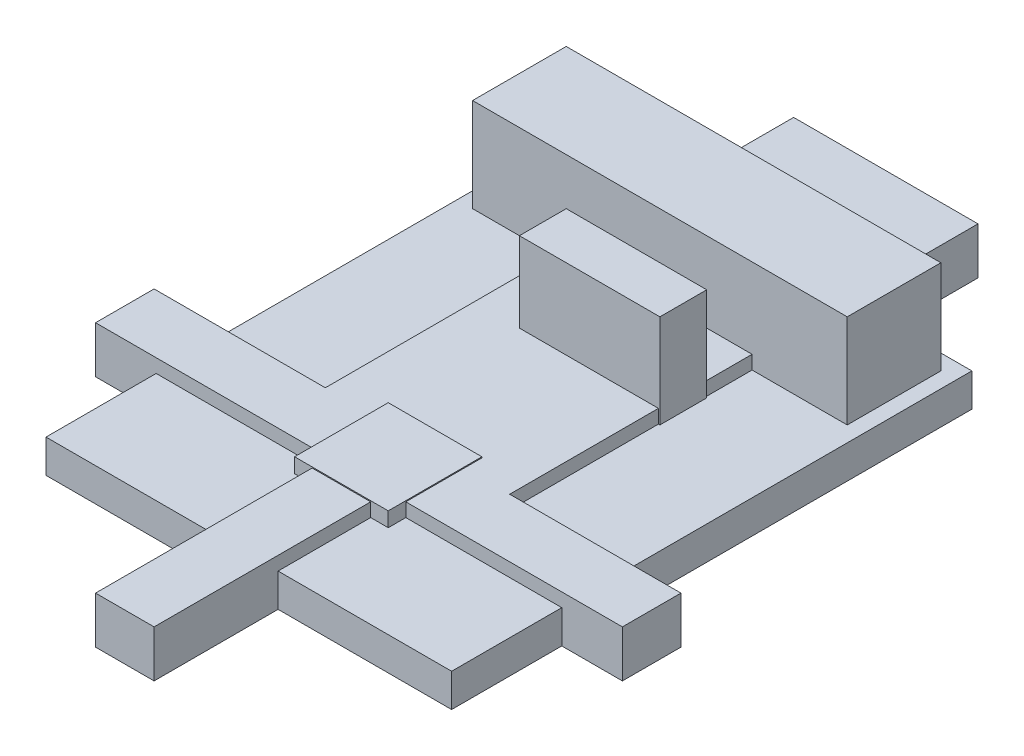
from build123d import *

# Parameters (mm, degrees)
SKETCH1_W           = 22
SKETCH1_H           = 28.216692514
BOSS_EXTRUDE1_DEPTH = 1.8
BOSS_EXTRUDE4_DEPTH = 2.54
SKETCH2_W           = 5.08
SKETCH2_H           = 5.08
BOSS_EXTRUDE2_DEPTH = 0.79375
BOSS_EXTRUDE3_START = -1.8
SKETCH3_W           = 7.62
SKETCH3_H           = 2.54
SKETCH3_W_2         = 20.32
SKETCH3_H_2         = 5.08
BOSS_EXTRUDE3_DEPTH = 5.08


with BuildPart() as part:
    # Sketch1 → Boss-Extrude1 (new body)
    with BuildSketch(Plane(origin=(0, 0, 0), x_dir=(1, 0, 0), z_dir=(0, 1, 0))):
        with Locations((0, 6.545846257)):
            Rectangle(SKETCH1_W, SKETCH1_H)
    extrude(amount=BOSS_EXTRUDE1_DEPTH)

    # Sketch4 → Boss-Extrude4 (add)
    with BuildSketch(Plane(origin=(0, 0, 0), x_dir=(1, 0, 0), z_dir=(0, 1, 0))):
        Polygon((-14.2875, -1.5875), (-1.5875, -1.5875), (-1.5875, -14.2875), (1.5875, -14.2875), (1.5875, -1.5875), (14.2875, -1.5875), (14.2875, 1.5875), (5, 1.5875), (5, 26.9875), (-5, 26.9875), (-5, 1.5875), (-14.2875, 1.5875), align=None)
    extrude(amount=BOSS_EXTRUDE4_DEPTH)

    # Sketch2 → Boss-Extrude2 (add)
    with BuildSketch(Plane(origin=(0, 1.8, 0), x_dir=(1, 0, 0), z_dir=(0, 1, 0))):
        Rectangle(SKETCH2_W, SKETCH2_H)
    extrude(amount=BOSS_EXTRUDE2_DEPTH)

    # Sketch3 → Boss-Extrude3 (add)
    with BuildSketch(Plane(origin=(0, 0, 0), x_dir=(-1, 0, 0), z_dir=(0, -1, 0)).offset(BOSS_EXTRUDE3_START)):
        with Locations((-1.27, 10.924192514)):
            Rectangle(SKETCH3_W, SKETCH3_H)
        with Locations((0, 17.274192514)):
            Rectangle(SKETCH3_W_2, SKETCH3_H_2)
    extrude(amount=-BOSS_EXTRUDE3_DEPTH)


solid = part.part
